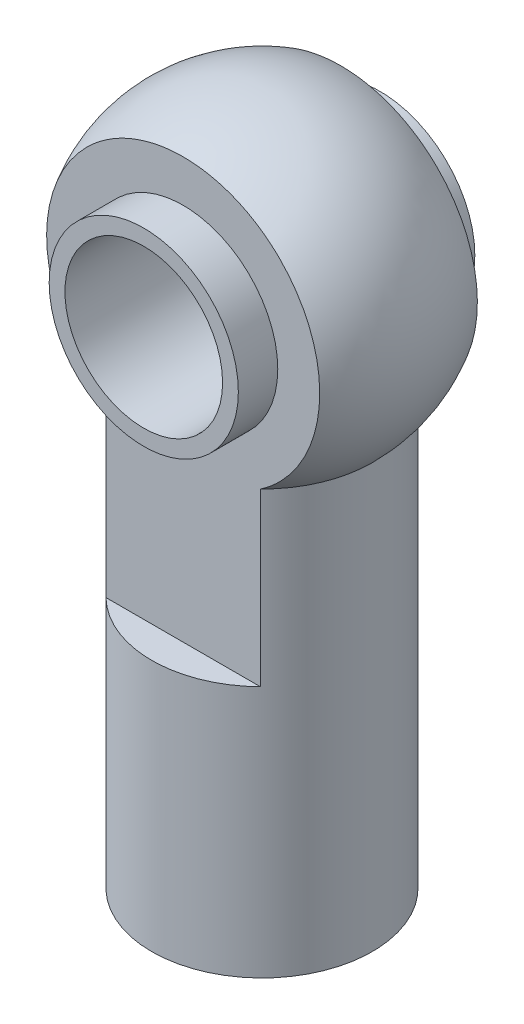
from build123d import *

# Parameters (mm, degrees)
SKETCH2_R               = 2.5
CUT_EXTRUDE1_DEPTH      = 6
CUT_EXTRUDE1_DEPTH_BACK = 6
SKETCH4_W               = 12
SKETCH4_H               = 18
CUT_EXTRUDE2_DEPTH      = 1.830127
SKETCH3_R               = 3
SKETCH3_R_2             = 2.5
EXTRUDE_THIN1_DEPTH     = 3.75


with BuildPart() as part:
    # Sketch1 → Revolve1 (revolve)
    with BuildSketch(Plane.XY):
        with BuildLine():
            Line((0, 0), (0, -7))
            Line((0, -7), (1.75, -7))
            Line((1.75, -7), (1.75, -17))
            Line((1.75, -17), (3.5, -17))
            Line((3.5, -17), (3.5, -3.570714214))
            ThreePointArc((3.5, -3.570714214), (4.628907596, 1.890294809), (0, 5))
            Line((0, 5), (0, 0))
        make_face()
    revolve(axis=Axis((0, 0, 0), (0, 1, 0)))

    # Sketch2 → Cut-Extrude1 (cut, two sides)
    with BuildSketch(Plane.XY) as cut_extrude1_sk:
        Circle(SKETCH2_R)
    extrude(amount=CUT_EXTRUDE1_DEPTH, mode=Mode.SUBTRACT)
    extrude(cut_extrude1_sk.sketch, amount=-CUT_EXTRUDE1_DEPTH_BACK, mode=Mode.SUBTRACT)

    # Sketch4 → Cut-Extrude2 (cut)
    with BuildSketch(Plane.XY.offset(2.5)):
        Rectangle(SKETCH4_W, SKETCH4_H)
    cut_extrude2 = extrude(amount=CUT_EXTRUDE2_DEPTH, mode=Mode.SUBTRACT)

    # Mirror1: Cut-Extrude2 across plane
    add(cut_extrude2.mirror(Plane.XY), mode=Mode.SUBTRACT)

    # Sketch3 → Extrude-Thin1 (add, symmetric)
    with BuildSketch(Plane.XY):
        Circle(SKETCH3_R)
        Circle(SKETCH3_R_2, mode=Mode.SUBTRACT)
    extrude(amount=EXTRUDE_THIN1_DEPTH, both=True)


solid = part.part
